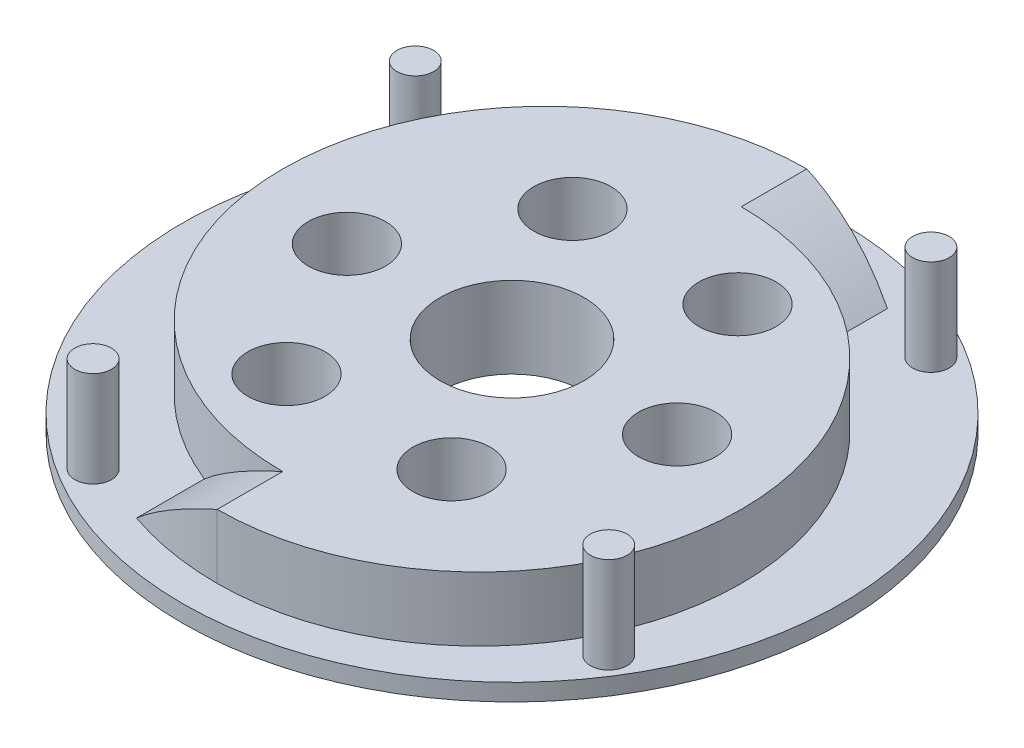
from build123d import *

# Parameters (mm, degrees)
SKETCH1_R          = 63.881
EXTRUDE1_DEPTH     = 3.302
EXTRUDE2_DEPTH     = 12.446
SKETCH5_R          = 13.97
CUT_EXTRUDE3_DEPTH = 16.748
SKETCH7_R          = 7.493
CUT_EXTRUDE4_DEPTH = 16.748
CIRPATTERN1_COUNT  = 6
EXTRUDE3_START     = 40.844813
EXTRUDE3_DEPTH     = 16.305187
CUT_EXTRUDE5_DEPTH = 12.446
EXTRUDE4_START     = -57.15
EXTRUDE4_DEPTH     = 16.305187
CUT_EXTRUDE6_DEPTH = 12.446
SKETCH22_R         = 3.556
EXTRUDE5_DEPTH     = 18.542
CIRPATTERN2_COUNT  = 4


with BuildPart() as part:
    # Sketch1 → Extrude1 (new body)
    with BuildSketch(Plane(origin=(0, 0, 0), x_dir=(1, 0, 0), z_dir=(0, 1, 0))):
        Circle(SKETCH1_R)
    extrude(amount=EXTRUDE1_DEPTH)

    # Sketch4 → Extrude2 (add)
    with BuildSketch(Plane(origin=(0, 3.302, 0), x_dir=(-1, 0, 0), z_dir=(0, 1, 0))):
        with BuildLine():
            Line((0, -57.15), (0, -44.45))
            ThreePointArc((0, -44.45), (-50.8, 6.35), (0, 57.15))
            Line((0, 57.15), (0, 44.45))
            ThreePointArc((0, 44.45), (50.8, -6.35), (0, -57.15))
        make_face()
    extrude(amount=EXTRUDE2_DEPTH)

    # Sketch5 → Cut-Extrude3 (cut, through all)
    with BuildSketch(Plane(origin=(0, 15.748, 0), x_dir=(-1, 0, 0), z_dir=(0, 1, 0))):
        Circle(SKETCH5_R)
    extrude(amount=-CUT_EXTRUDE3_DEPTH, mode=Mode.SUBTRACT)

    # Sketch7 → Cut-Extrude4 (cut, through all)
    with BuildSketch(Plane(origin=(0, 15.748, 0), x_dir=(-1, 0, 0), z_dir=(0, 1, 0))):
        with Locations((-32.004, 0)):
            Circle(SKETCH7_R)
    cut_extrude4 = extrude(amount=-CUT_EXTRUDE4_DEPTH, mode=Mode.SUBTRACT)

    # CirPattern1: Cut-Extrude4 ×6 about axis
    cirpattern1_axis = Axis((0, 0, 0), (0, 1, 0))
    for i in range(1, CIRPATTERN1_COUNT):
        add(cut_extrude4.rotate(cirpattern1_axis, i * 360 / CIRPATTERN1_COUNT), mode=Mode.SUBTRACT)

    # Sketch18 → Extrude3 (add)
    with BuildSketch(Plane.XY.offset(EXTRUDE3_START)):
        with BuildLine():
            Line((0, 3.302), (-18.796, 3.302))
            ThreePointArc((-18.796, 3.302), (-9.88893997, 10.266419547), (0, 15.748))
            Line((0, 15.748), (0, 3.302))
        make_face()
    extrude(amount=EXTRUDE3_DEPTH)

    # Sketch19 → Cut-Extrude5 (cut)
    with BuildSketch(Plane(origin=(0, 15.748, 0), x_dir=(-1, 0, 0), z_dir=(0, 1, 0))):
        with BuildLine():
            Line((18.796, 53.970666885), (18.796, 57.15))
            Line((18.796, 57.15), (0, 57.15))
            ThreePointArc((0, 57.15), (9.531497457, 56.349561278), (18.796, 53.970666885))
        make_face()
    extrude(amount=-CUT_EXTRUDE5_DEPTH, mode=Mode.SUBTRACT)

    # Sketch20 → Extrude4 (add)
    with BuildSketch(Plane.XY.offset(EXTRUDE4_START)):
        with BuildLine():
            Line((0, 3.302), (18.796, 3.302))
            ThreePointArc((18.796, 3.302), (9.88893997, 10.266419547), (0, 15.748))
            Line((0, 15.748), (0, 3.302))
        make_face()
    extrude(amount=EXTRUDE4_DEPTH)

    # Sketch21 → Cut-Extrude6 (cut)
    with BuildSketch(Plane(origin=(0, 15.748, 0), x_dir=(-1, 0, 0), z_dir=(0, 1, 0))):
        with BuildLine():
            Line((0, -57.15), (-18.796, -57.15))
            Line((-18.796, -57.15), (-18.796, -53.970666885))
            ThreePointArc((-18.796, -53.970666885), (-9.531497457, -56.349561278), (0, -57.15))
        make_face()
    extrude(amount=-CUT_EXTRUDE6_DEPTH, mode=Mode.SUBTRACT)

    # Sketch22 → Extrude5 (add)
    with BuildSketch(Plane(origin=(0, 3.302, 57.15), x_dir=(1, 0, 0), z_dir=(0, -1, 0))):
        with Locations((49.97377821, -25.922917597)):
            Circle(SKETCH22_R)
    extrude5 = extrude(amount=-EXTRUDE5_DEPTH)

    # CirPattern2: Extrude5 ×4 about axis
    cirpattern2_axis = Axis((0, 0, 0), (0, 1, 0))
    for i in range(1, CIRPATTERN2_COUNT):
        add(extrude5.rotate(cirpattern2_axis, i * 360 / CIRPATTERN2_COUNT))


solid = part.part
